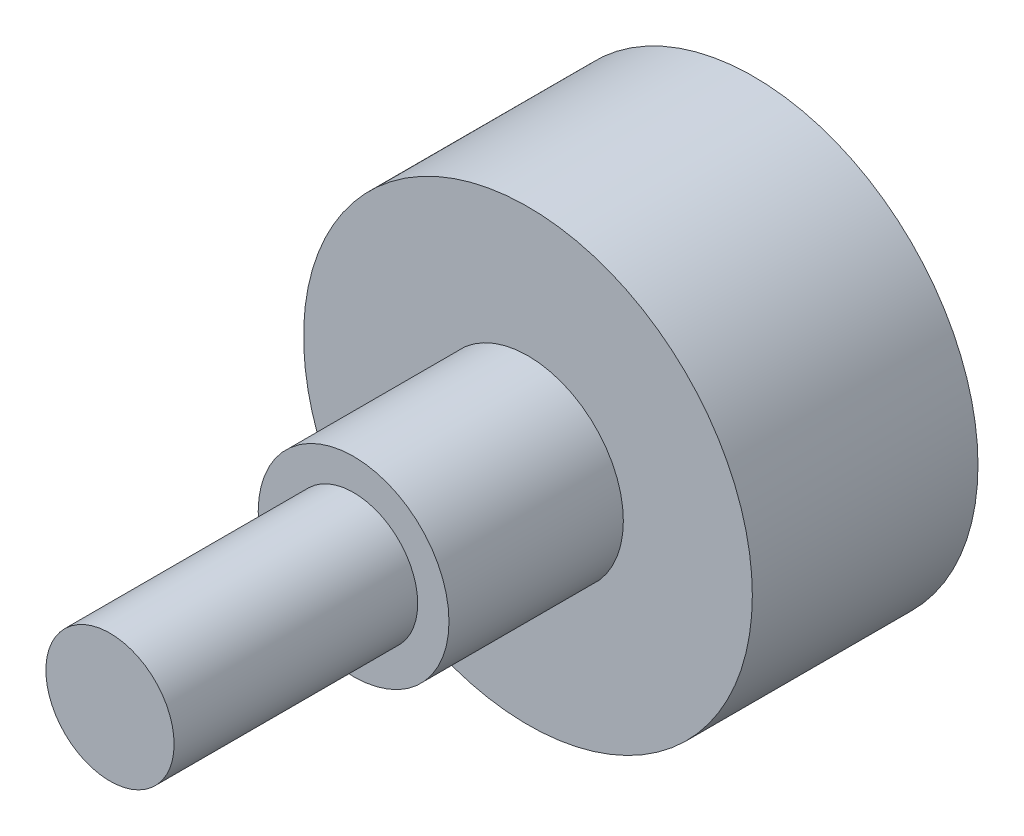
from build123d import *

# Parameters (mm, degrees)
SKETCH1_R           = 11.1125
BOSS_EXTRUDE1_DEPTH = 11.176
SKETCH2_R           = 4.7244
BOSS_EXTRUDE2_DEPTH = 8.636
SKETCH3_R           = 3.175
BOSS_EXTRUDE3_DEPTH = 12.065


with BuildPart() as part:
    # Sketch1 → Boss-Extrude1 (new body)
    with BuildSketch(Plane.XY):
        Circle(SKETCH1_R)
    extrude(amount=BOSS_EXTRUDE1_DEPTH)

    # Sketch2 → Boss-Extrude2 (add)
    with BuildSketch(Plane.XY.offset(11.176)):
        Circle(SKETCH2_R)
    extrude(amount=BOSS_EXTRUDE2_DEPTH)

    # Sketch3 → Boss-Extrude3 (add)
    with BuildSketch(Plane.XY.offset(19.812)):
        Circle(SKETCH3_R)
    extrude(amount=BOSS_EXTRUDE3_DEPTH)


solid = part.part
